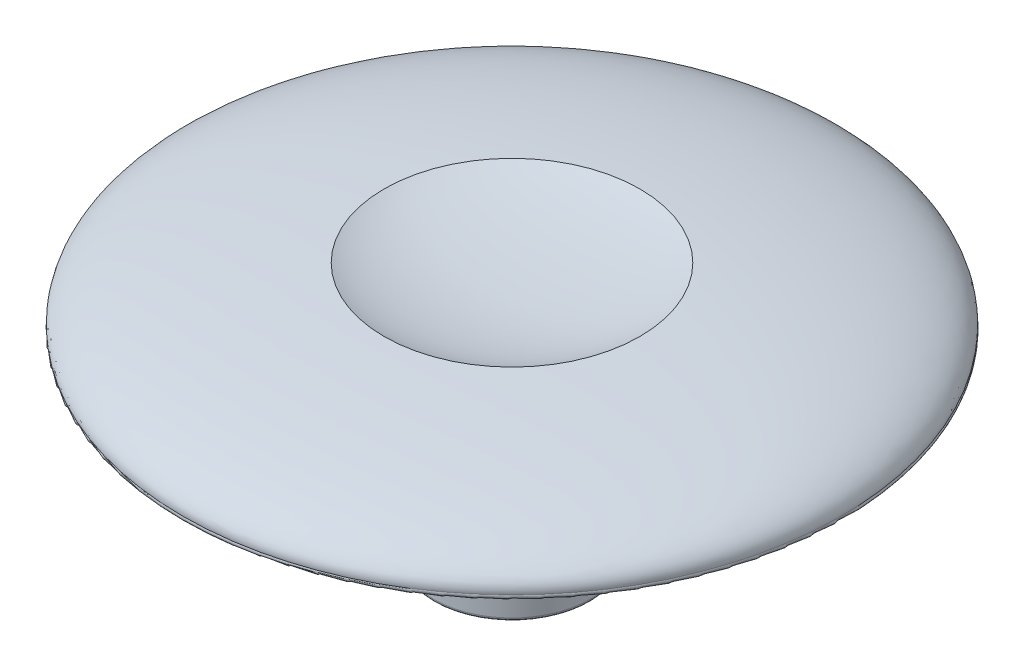
from build123d import *


with BuildPart() as part:
    # Sketch1 → Revolve1 (revolve)
    with BuildSketch(Plane(origin=(0, 0, 0), x_dir=(0, 0, -1), z_dir=(1, 0, 0))):
        with BuildLine():
            Line((0, 0), (0.7, 0))
            Line((0.7, 0), (0.7, -2.95))
            ThreePointArc((0.7, -2.95), (0.714644661, -2.985355339), (0.75, -3))
            Line((0.75, -3), (1.15, -3))
            ThreePointArc((1.15, -3), (1.185355339, -2.985355339), (1.2, -2.95))
            Line((1.2, -2.95), (1.2, -0.1))
            Line((1.2, -0.1), (2, -0.1))
            Line((2, -0.1), (2, 0))
            Line((2, 0), (5, 0))
            ThreePointArc((5, 0), (5.042871169, 0.024269418), (5.044124005, 0.073517487))
            add(Edge.make_bspline(
                [(5.044124005, 0.073517487), (5.150084824, 0.728367306), (1.959714512, 0.917022897)],
                knots=[6.248596197, 6.248596197, 6.248596197, 7.451182248, 7.451182248, 7.451182248], degree=2, weights=[1, 0.824604828, 1]))
            add(Edge.make_bspline(
                [(0, 0.628352907), (1.302459015, 0.625404776), (1.959714512, 0.917022897)],
                knots=[4.703660792, 4.703660792, 4.703660792, 5.754258139, 5.754258139, 5.754258139], degree=2, weights=[1, 0.865174204, 1]))
            Line((0, 0.628352907), (0, 0))
        make_face()
    revolve(axis=Axis((0, 0.628352907, 0), (0, -1, 0)))


solid = part.part
